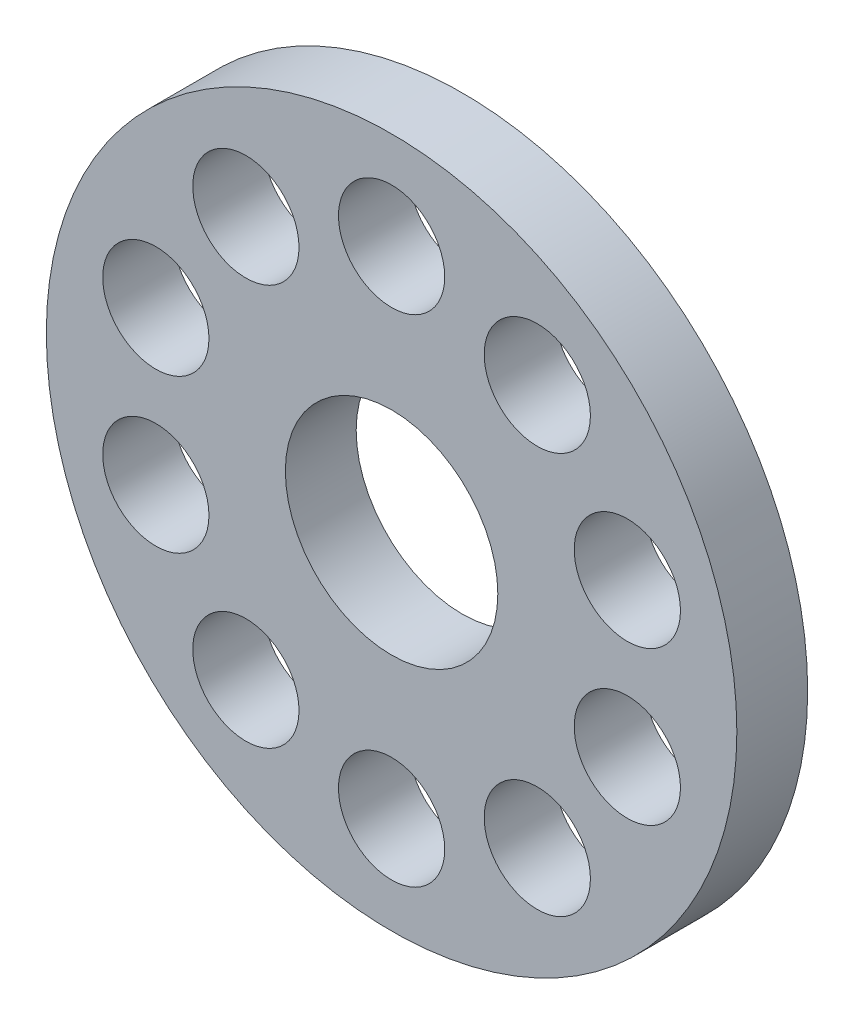
from build123d import *

# Parameters (mm, degrees)
SKETCH1_R           = 9.75
SKETCH1_R_2         = 3
SKETCH1_R_3         = 1.5
BOSS_EXTRUDE1_DEPTH = 2


with BuildPart() as part:
    # Sketch1 → Boss-Extrude1 (new body)
    with BuildSketch(Plane.XY):
        Circle(SKETCH1_R)
        Circle(SKETCH1_R_2, mode=Mode.SUBTRACT)
        with Locations((0, 7)):
            Circle(SKETCH1_R_3, mode=Mode.SUBTRACT)
        with Locations((4.114496766, 5.663118961)):
            Circle(SKETCH1_R_3, mode=Mode.SUBTRACT)
        with Locations((6.657395614, 2.163118961)):
            Circle(SKETCH1_R_3, mode=Mode.SUBTRACT)
        with Locations((6.657395614, -2.163118961)):
            Circle(SKETCH1_R_3, mode=Mode.SUBTRACT)
        with Locations((4.114496766, -5.663118961)):
            Circle(SKETCH1_R_3, mode=Mode.SUBTRACT)
        with Locations((0, -7)):
            Circle(SKETCH1_R_3, mode=Mode.SUBTRACT)
        with Locations((-4.114496766, -5.663118961)):
            Circle(SKETCH1_R_3, mode=Mode.SUBTRACT)
        with Locations((-6.657395614, -2.163118961)):
            Circle(SKETCH1_R_3, mode=Mode.SUBTRACT)
        with Locations((-6.657395614, 2.163118961)):
            Circle(SKETCH1_R_3, mode=Mode.SUBTRACT)
        with Locations((-4.114496766, 5.663118961)):
            Circle(SKETCH1_R_3, mode=Mode.SUBTRACT)
    extrude(amount=-BOSS_EXTRUDE1_DEPTH)


solid = part.part
